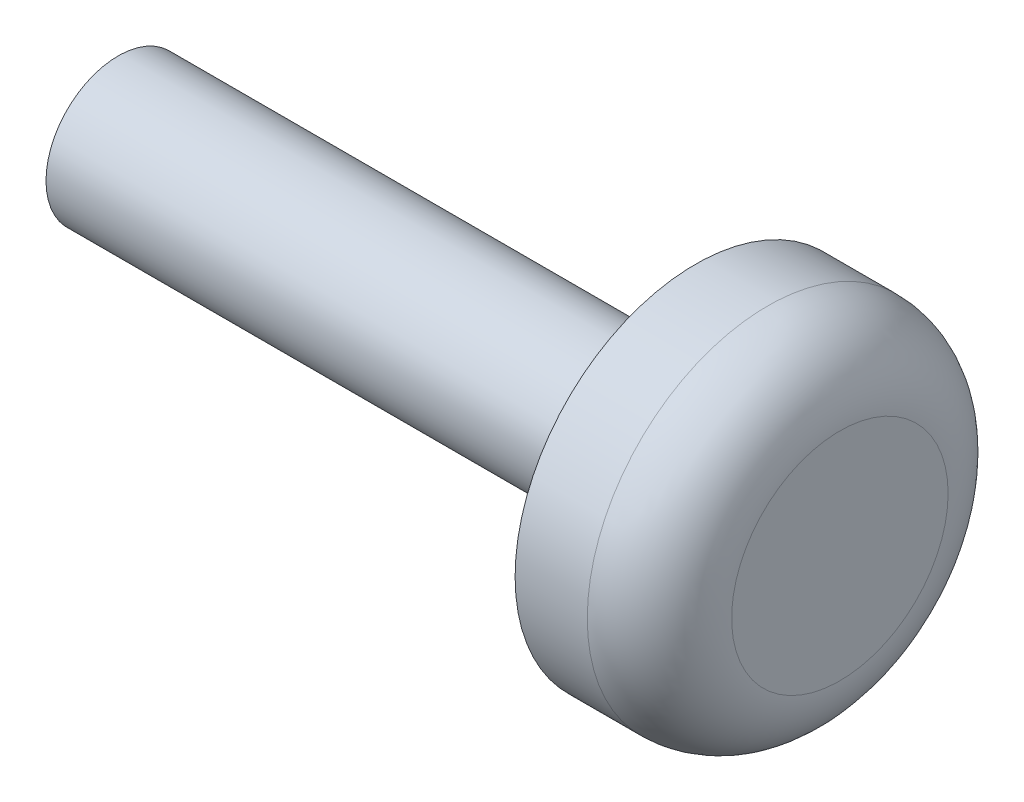
from build123d import *

# Parameters (mm, degrees)
SKIZZE1_R                       = 2.5
AUFSATZ_LINEAR_AUSTRAGEN1_DEPTH = 2
SKIZZE2_R                       = 1
AUFSATZ_LINEAR_AUSTRAGEN2_DEPTH = 8
VERRUNDUNG1_R                   = 1


with BuildPart() as part:
    # Skizze1 → Aufsatz-Linear austragen1 (new body)
    with BuildSketch(Plane(origin=(0, 0, 0), x_dir=(0, 0, -1), z_dir=(1, 0, 0))):
        Circle(SKIZZE1_R)
    extrude(amount=AUFSATZ_LINEAR_AUSTRAGEN1_DEPTH)

    # Skizze2 → Aufsatz-Linear austragen2 (add)
    with BuildSketch(Plane.ZY):
        Circle(SKIZZE2_R)
    extrude(amount=AUFSATZ_LINEAR_AUSTRAGEN2_DEPTH)

    # Verrundung1
    verrundung1_edges = [part.edges().sort_by_distance(p)[0] for p in [
        (2, 0, 2.5),
    ]]
    fillet(verrundung1_edges, radius=VERRUNDUNG1_R)


solid = part.part
